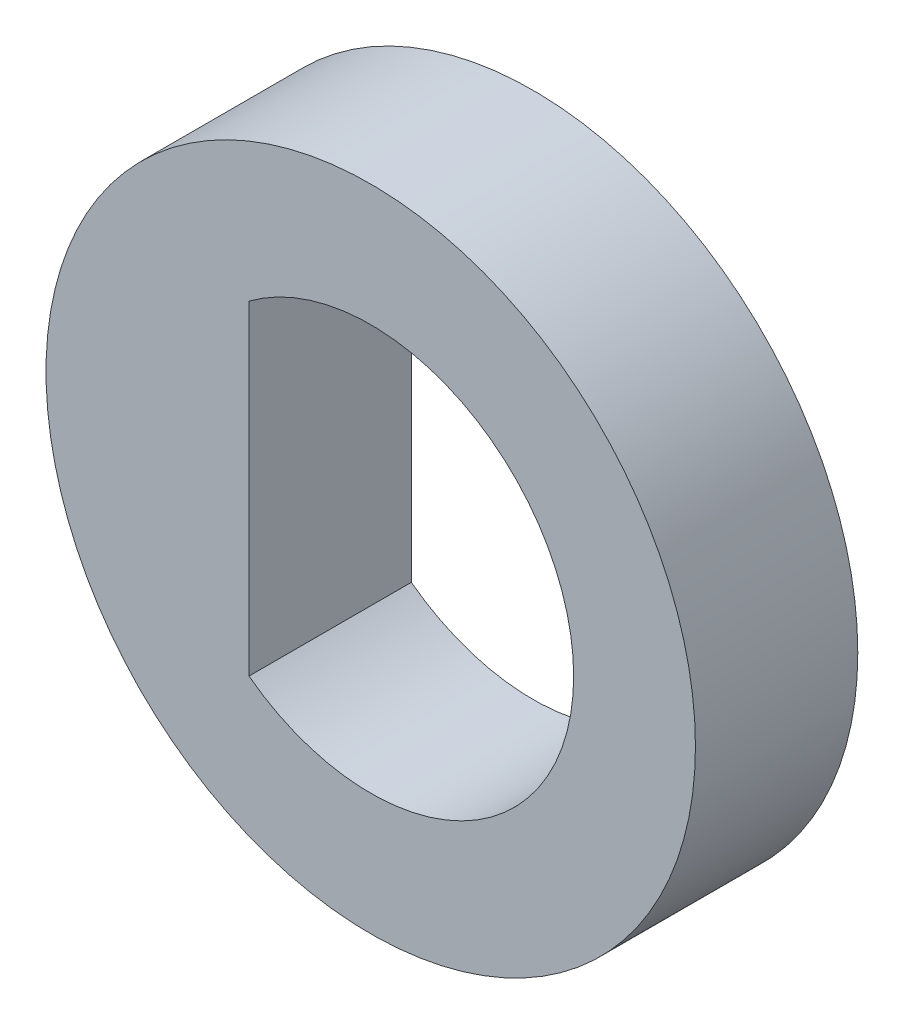
from build123d import *

# Parameters (mm, degrees)
SKETCH1_R           = 4
BOSS_EXTRUDE1_DEPTH = 2


with BuildPart() as part:
    # Sketch1 → Boss-Extrude1 (new body)
    with BuildSketch(Plane.XY):
        Circle(SKETCH1_R)
        with BuildLine():
            Line((-1.5, 2), (-1.5, -2))
            ThreePointArc((-1.5, -2), (2.5, 0), (-1.5, 2))
        make_face(mode=Mode.SUBTRACT)
    extrude(amount=BOSS_EXTRUDE1_DEPTH)


solid = part.part
